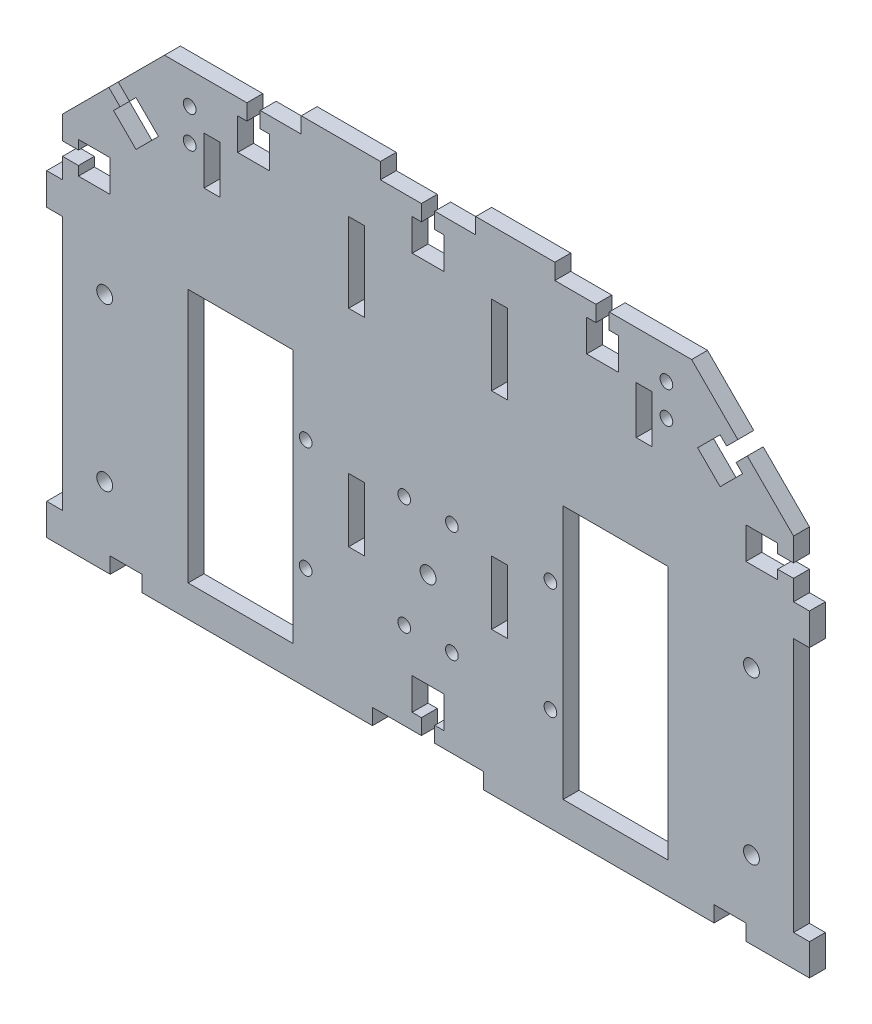
from build123d import *

# Parameters (mm, degrees)
BOSS_EXTRUDE1_DEPTH  = 5
BOSS_EXTRUDE2_DEPTH  = 5
SKETCH3_R            = 2
SKETCH3_R_2          = 2.5
CUT_EXTRUDE4_DEPTH   = 10
SKETCH6_R            = 2.5
CUT_EXTRUDE5_DEPTH   = 10
CUT_EXTRUDE6_DEPTH   = 10
SKETCH9_W            = 35
SKETCH9_H            = 5
SKETCH9_W_2          = 4.2
SKETCH9_W_3          = 10
SKETCH9_H_2          = 10
CUT_EXTRUDE7_DEPTH   = 10
SKETCH10_W           = 30.598870639
SKETCH10_H           = 58.148019952
CUT_EXTRUDE8_DEPTH   = 5
SKETCH11_W           = 30
SKETCH11_H           = 5
CUT_EXTRUDE9_DEPTH   = 5
SKETCH12_W           = 5
SKETCH12_H           = 80
BOSS_EXTRUDE3_DEPTH  = 4.5
SKETCH13_W           = 5
SKETCH13_H           = 80
BOSS_EXTRUDE4_DEPTH  = 4.5
SKETCH14_W           = 5
SKETCH14_H           = 5
BOSS_EXTRUDE5_DEPTH  = 0.1
SKETCH15_W           = 5
SKETCH15_H           = 5
CUT_EXTRUDE10_DEPTH  = 0.1
SKETCH16_W           = 5
SKETCH16_H           = 5
BOSS_EXTRUDE6_DEPTH  = 0.1
SKETCH17_W           = 5
SKETCH17_H           = 5
CUT_EXTRUDE11_DEPTH  = 0.1
SKETCH18_W           = 315.275634843
SKETCH18_H           = 155.272188677
CUT_EXTRUDE12_DEPTH  = 0.1
SKETCH19_W           = 15.4
SKETCH19_H           = 5
CUT_EXTRUDE13_DEPTH  = 0.1
CUT_EXTRUDE14_DEPTH  = 5
SKETCH21_W           = 5
SKETCH21_H           = 4.2
SKETCH21_W_2         = 3.2
SKETCH21_W_3         = 1.8
SKETCH21_H_2         = 1.4
CUT_EXTRUDE15_DEPTH  = 5
SKETCH22_W           = 5
SKETCH22_H           = 25
CUT_EXTRUDE16_DEPTH  = 10
SKETCH23_R           = 2
CUT_EXTRUDE17_DEPTH  = 10
CUT_EXTRUDE18_DEPTH  = 10
SKETCH25_W           = 5
SKETCH25_H           = 5
BOSS_EXTRUDE7_DEPTH  = 5
SKETCH28_W           = 10
SKETCH28_H           = 5
CUT_EXTRUDE19_DEPTH  = 5
SKETCH30_W           = 5
SKETCH30_H           = 15
CUT_EXTRUDE21_DEPTH  = 5
SKETCH31_W           = 10
SKETCH31_H           = 10
CUT_EXTRUDE22_DEPTH  = 10
SKETCH32_W           = 5
SKETCH32_H           = 10
CUT_EXTRUDE23_DEPTH  = 5
SKETCH33_W           = 5
SKETCH33_H           = 10
CUT_EXTRUDE24_DEPTH  = 5
SKETCH34_W           = 5
SKETCH34_H           = 80
BOSS_EXTRUDE10_DEPTH = 17.5
SKETCH35_W           = 5
SKETCH35_H           = 80
BOSS_EXTRUDE11_DEPTH = 17.5


with BuildPart() as part:
    # Sketch1 → Boss-Extrude1 (new body)
    with BuildSketch(Plane.XY):
        Polygon((-42.5, -104.9), (42.5, -104.9), (42.5, -49.9), (42.5, -37.4), (120, -37.4), (120, -17.4), (115, -17.4), (115, 12.8), (120, 12.8), (120, 27.7), (100.1, 27.7), (100.1, 22.7), (39.9, 22.7), (39.9, 27.7), (-39.9, 27.7), (-39.9, 22.7), (-100.1, 22.7), (-100.1, 27.7), (-120, 27.7), (-120, 12.8), (-115, 12.8), (-115, -17.4), (-120, -17.4), (-120, -37.4), (-42.5, -37.4), (-42.5, -49.9), align=None)
    extrude(amount=BOSS_EXTRUDE1_DEPTH)

    # Sketch2 → Boss-Extrude2 (add)
    with BuildSketch(Plane.XY.offset(5)):
        Polygon((-2.1, -104.9), (-42.5, -104.9), (-42.5, -117.4), (-93, -117.4), (-93, -37.4), (-110.5, -37.4), (-110.5, -117.4), (-120, -117.4), (-120, -127.4), (120, -127.4), (120, -117.4), (110.5, -117.4), (110.5, -37.4), (93, -37.4), (93, -117.4), (42.5, -117.4), (42.5, -104.9), (2.1, -104.9), align=None)
    extrude(amount=-BOSS_EXTRUDE2_DEPTH)

    # Sketch3 → Cut-Extrude4 (cut)
    with BuildSketch(Plane.XY.offset(5)):
        with Locations((-38.5, -59.9)):
            Circle(SKETCH3_R)
        with Locations((-38.5, -94.9)):
            Circle(SKETCH3_R)
        with Locations((-7.5, -94.9)):
            Circle(SKETCH3_R)
        with Locations((-7.5, -59.9)):
            Circle(SKETCH3_R)
        with Locations((38.5, -94.9)):
            Circle(SKETCH3_R)
        with Locations((7.5, -94.9)):
            Circle(SKETCH3_R)
        with Locations((7.5, -59.9)):
            Circle(SKETCH3_R)
        with Locations((38.5, -59.9)):
            Circle(SKETCH3_R)
        with Locations((0, -77.4)):
            Circle(SKETCH3_R_2)
    extrude(amount=-CUT_EXTRUDE4_DEPTH, mode=Mode.SUBTRACT)

    # Sketch6 → Cut-Extrude5 (cut)
    with BuildSketch(Plane.XY.offset(5)):
        with Locations((-101.75, -51.9)):
            Circle(SKETCH6_R)
        with Locations((-101.75, -102.9)):
            Circle(SKETCH6_R)
        with Locations((101.75, -102.9)):
            Circle(SKETCH6_R)
        with Locations((101.75, -51.9)):
            Circle(SKETCH6_R)
    extrude(amount=-CUT_EXTRUDE5_DEPTH, mode=Mode.SUBTRACT)

    # Sketch8 → Cut-Extrude6 (cut)
    with BuildSketch(Plane.XY.offset(5)):
        Polygon((-115, 22.7), (-90, 22.7), (-115, -2.3), align=None)
        Polygon((-115, 22.7), (-100.1, 22.7), (-100.1, 27.7), (-120, 27.7), (-120, 12.8), (-115, 12.8), align=None)
        Polygon((100.1, 22.7), (115, 22.7), (115, 12.8), (120, 12.8), (120, 27.7), (100.1, 27.7), align=None)
        Polygon((115, 12.8), (115, 22.7), (100.1, 22.7), (90, 22.7), (115, -2.3), align=None)
    extrude(amount=-CUT_EXTRUDE6_DEPTH, mode=Mode.SUBTRACT)

    # Sketch9 → Cut-Extrude7 (cut)
    with BuildSketch(Plane.XY.offset(5)):
        with Locations((0, -124.9)):
            Rectangle(SKETCH9_W, SKETCH9_H)
        with Locations((0, -119.9)):
            Rectangle(SKETCH9_W_2, SKETCH9_H)
        with Locations((0, -112.4)):
            Rectangle(SKETCH9_W_3, SKETCH9_H_2)
    extrude(amount=-CUT_EXTRUDE7_DEPTH, mode=Mode.SUBTRACT)

    # Sketch10 → Cut-Extrude8 (cut)
    with BuildSketch(Plane(origin=(-56.35, 56.35, 0), x_dir=(0, 0, 1), z_dir=(-0.707106781, 0.707106781, 0))):
        with Locations((4.930158629, -62.874909177)):
            Rectangle(SKETCH10_W, SKETCH10_H)
    cut_extrude8 = extrude(amount=-CUT_EXTRUDE8_DEPTH, mode=Mode.SUBTRACT)

    # Mirror1: Cut-Extrude8 across plane
    add(cut_extrude8.mirror(Plane(origin=(0, 0, 0), x_dir=(0, 0, 1), z_dir=(1, 0, 0))), mode=Mode.SUBTRACT)

    # Sketch11 → Cut-Extrude9 (cut)
    with BuildSketch(Plane.XY.offset(5)):
        with Locations((0, 25.2)):
            Rectangle(SKETCH11_W, SKETCH11_H)
    extrude(amount=-CUT_EXTRUDE9_DEPTH, mode=Mode.SUBTRACT)

    # Sketch12 → Boss-Extrude3 (add)
    with BuildSketch(Plane(origin=(110.5, 0, 0), x_dir=(0, 0, -1), z_dir=(1, 0, 0))):
        with Locations((-2.5, -77.4)):
            Rectangle(SKETCH12_W, SKETCH12_H)
    extrude(amount=BOSS_EXTRUDE3_DEPTH)

    # Sketch13 → Boss-Extrude4 (add)
    with BuildSketch(Plane.ZY.offset(110.5)):
        with Locations((2.5, -77.4)):
            Rectangle(SKETCH13_W, SKETCH13_H)
    extrude(amount=BOSS_EXTRUDE4_DEPTH)

    # Sketch14 → Boss-Extrude5 (add)
    with BuildSketch(Plane(origin=(0, -17.4, 0), x_dir=(1, 0, 0), z_dir=(0, 1, 0))):
        with Locations((117.5, -2.5)):
            Rectangle(SKETCH14_W, SKETCH14_H)
    extrude(amount=BOSS_EXTRUDE5_DEPTH)

    # Sketch15 → Cut-Extrude10 (cut)
    with BuildSketch(Plane.XZ.offset(37.4)):
        with Locations((117.5, 2.5)):
            Rectangle(SKETCH15_W, SKETCH15_H)
    extrude(amount=-CUT_EXTRUDE10_DEPTH, mode=Mode.SUBTRACT)

    # Sketch16 → Boss-Extrude6 (add)
    with BuildSketch(Plane(origin=(0, -17.4, 0), x_dir=(1, 0, 0), z_dir=(0, 1, 0))):
        with Locations((-117.5, -2.5)):
            Rectangle(SKETCH16_W, SKETCH16_H)
    extrude(amount=BOSS_EXTRUDE6_DEPTH)

    # Sketch17 → Cut-Extrude11 (cut)
    with BuildSketch(Plane.XZ.offset(37.4)):
        with Locations((-117.5, 2.5)):
            Rectangle(SKETCH17_W, SKETCH17_H)
    extrude(amount=-CUT_EXTRUDE11_DEPTH, mode=Mode.SUBTRACT)

    # Sketch18 → Cut-Extrude12 (cut)
    with BuildSketch(Plane.XZ.offset(127.4)):
        with Locations((9.753929885, -1.918428582)):
            Rectangle(SKETCH18_W, SKETCH18_H)
    extrude(amount=-CUT_EXTRUDE12_DEPTH, mode=Mode.SUBTRACT)

    # Sketch19 → Cut-Extrude13 (cut)
    with BuildSketch(Plane.XZ.offset(122.4)):
        with Locations((9.8, 2.5)):
            Rectangle(SKETCH19_W, SKETCH19_H)
        with Locations((-9.8, 2.5)):
            Rectangle(SKETCH19_W, SKETCH19_H)
    extrude(amount=-CUT_EXTRUDE13_DEPTH, mode=Mode.SUBTRACT)

    # Sketch20 → Cut-Extrude14 (cut)
    with BuildSketch(Plane.XY.offset(5)):
        Polygon((-97.479541854, 8.149390335), (-100.449390335, 5.179541854), (-96.913856429, 1.644007948), (-93.944007948, 4.613856429), align=None)
        Polygon((-91.893398282, 6.664466094), (-98.964466094, -0.406601718), (-91.893398282, -7.47766953), (-84.82233047, -0.406601718), align=None)
    cut_extrude14 = extrude(amount=-CUT_EXTRUDE14_DEPTH, mode=Mode.SUBTRACT)

    # Mirror2: Cut-Extrude14 across plane
    add(cut_extrude14.mirror(Plane(origin=(0, 0, 0), x_dir=(0, 0, 1), z_dir=(1, 0, 0))), mode=Mode.SUBTRACT)

    # Sketch21 → Cut-Extrude15 (cut)
    with BuildSketch(Plane.XY.offset(5)):
        with Locations((-112.5, -18.8)):
            Rectangle(SKETCH21_W, SKETCH21_H)
        with Locations((-108.4, -18.8)):
            Rectangle(SKETCH21_W_2, SKETCH21_H)
        with Locations((-105.9, -18.8)):
            Rectangle(SKETCH21_W_3, SKETCH21_H)
        with Locations((-108.4, -16)):
            Rectangle(SKETCH21_W_2, SKETCH21_H_2)
        with Locations((-108.4, -21.6)):
            Rectangle(SKETCH21_W_2, SKETCH21_H_2)
    cut_extrude15 = extrude(amount=-CUT_EXTRUDE15_DEPTH, mode=Mode.SUBTRACT)

    # Sketch22 → Cut-Extrude16 (cut)
    with BuildSketch(Plane.XY.offset(5)):
        with Locations((22.5, -69.8)):
            Rectangle(SKETCH22_W, SKETCH22_H)
        with Locations((22.5, -4.8)):
            Rectangle(SKETCH22_W, SKETCH22_H)
        with Locations((-22.5, -4.8)):
            Rectangle(SKETCH22_W, SKETCH22_H)
        with Locations((-22.5, -69.8)):
            Rectangle(SKETCH22_W, SKETCH22_H)
    extrude(amount=-CUT_EXTRUDE16_DEPTH, mode=Mode.SUBTRACT)

    # Sketch23 → Cut-Extrude17 (cut)
    with BuildSketch(Plane.XY.offset(5)):
        with Locations((75, 12.7)):
            Circle(SKETCH23_R)
        with Locations((75, 2.7)):
            Circle(SKETCH23_R)
        with Locations((-75, 2.7)):
            Circle(SKETCH23_R)
        with Locations((-75, 12.7)):
            Circle(SKETCH23_R)
    extrude(amount=-CUT_EXTRUDE17_DEPTH, mode=Mode.SUBTRACT)

    # Mirror3: Cut-Extrude15 across plane
    add(cut_extrude15.mirror(Plane(origin=(0, 0, 0), x_dir=(0, 0, 1), z_dir=(1, 0, 0))), mode=Mode.SUBTRACT)

    # Sketch24 → Cut-Extrude18 (cut)
    with BuildSketch(Plane.XY.offset(5)):
        Polygon((-52.8, 17.7), (-52.8, 22.7), (-57, 22.7), (-57, 17.7), (-59.9, 17.7), (-59.9, 7.7), (-49.9, 7.7), (-49.9, 17.7), align=None)
        Polygon((59.9, 7.7), (59.9, 17.7), (57, 17.7), (57, 22.7), (52.8, 22.7), (52.8, 17.7), (49.9, 17.7), (49.9, 7.7), align=None)
        Polygon((2.1, 17.7), (2.1, 22.7), (-2.1, 22.7), (-2.1, 17.7), (-5, 17.7), (-5, 7.7), (5, 7.7), (5, 17.7), align=None)
    extrude(amount=-CUT_EXTRUDE18_DEPTH, mode=Mode.SUBTRACT)

    # Sketch25 → Boss-Extrude7 (add)
    with BuildSketch(Plane.XY.offset(5)):
        with Locations((-22.5, -59.8)):
            Rectangle(SKETCH25_W, SKETCH25_H)
        with Locations((22.5, -59.8)):
            Rectangle(SKETCH25_W, SKETCH25_H)
    extrude(amount=-BOSS_EXTRUDE7_DEPTH)

    # Sketch28 → Cut-Extrude19 (cut)
    with BuildSketch(Plane.XY.offset(5)):
        with Locations((-95, -124.8)):
            Rectangle(SKETCH28_W, SKETCH28_H)
        with Locations((95, -124.8)):
            Rectangle(SKETCH28_W, SKETCH28_H)
    extrude(amount=-CUT_EXTRUDE19_DEPTH, mode=Mode.SUBTRACT)

    # Sketch30 → Cut-Extrude21 (cut)
    with BuildSketch(Plane.XY.offset(5)):
        with Locations((-68, 0.2)):
            Rectangle(SKETCH30_W, SKETCH30_H)
        with Locations((68, 0.2)):
            Rectangle(SKETCH30_W, SKETCH30_H)
    extrude(amount=-CUT_EXTRUDE21_DEPTH, mode=Mode.SUBTRACT)

    # Sketch31 → Cut-Extrude22 (cut)
    with BuildSketch(Plane.XY.offset(5)):
        with Locations((105, -18.8)):
            Rectangle(SKETCH31_W, SKETCH31_H)
        with Locations((-105, -18.8)):
            Rectangle(SKETCH31_W, SKETCH31_H)
    extrude(amount=-CUT_EXTRUDE22_DEPTH, mode=Mode.SUBTRACT)

    # Sketch32 → Cut-Extrude23 (cut)
    with BuildSketch(Plane.XY.offset(5)):
        with Locations((-117.5, -22.3)):
            Rectangle(SKETCH32_W, SKETCH32_H)
    extrude(amount=-CUT_EXTRUDE23_DEPTH, mode=Mode.SUBTRACT)

    # Sketch33 → Cut-Extrude24 (cut)
    with BuildSketch(Plane.XY.offset(5)):
        with Locations((117.5, -22.3)):
            Rectangle(SKETCH33_W, SKETCH33_H)
    extrude(amount=-CUT_EXTRUDE24_DEPTH, mode=Mode.SUBTRACT)

    # Sketch34 → Boss-Extrude10 (add)
    with BuildSketch(Plane.ZY.offset(-93)):
        with Locations((2.5, -77.4)):
            Rectangle(SKETCH34_W, SKETCH34_H)
    extrude(amount=BOSS_EXTRUDE10_DEPTH)

    # Sketch35 → Boss-Extrude11 (add)
    with BuildSketch(Plane(origin=(-93, 0, 0), x_dir=(0, 0, -1), z_dir=(1, 0, 0))):
        with Locations((-2.5, -77.4)):
            Rectangle(SKETCH35_W, SKETCH35_H)
    extrude(amount=BOSS_EXTRUDE11_DEPTH)


solid = part.part
